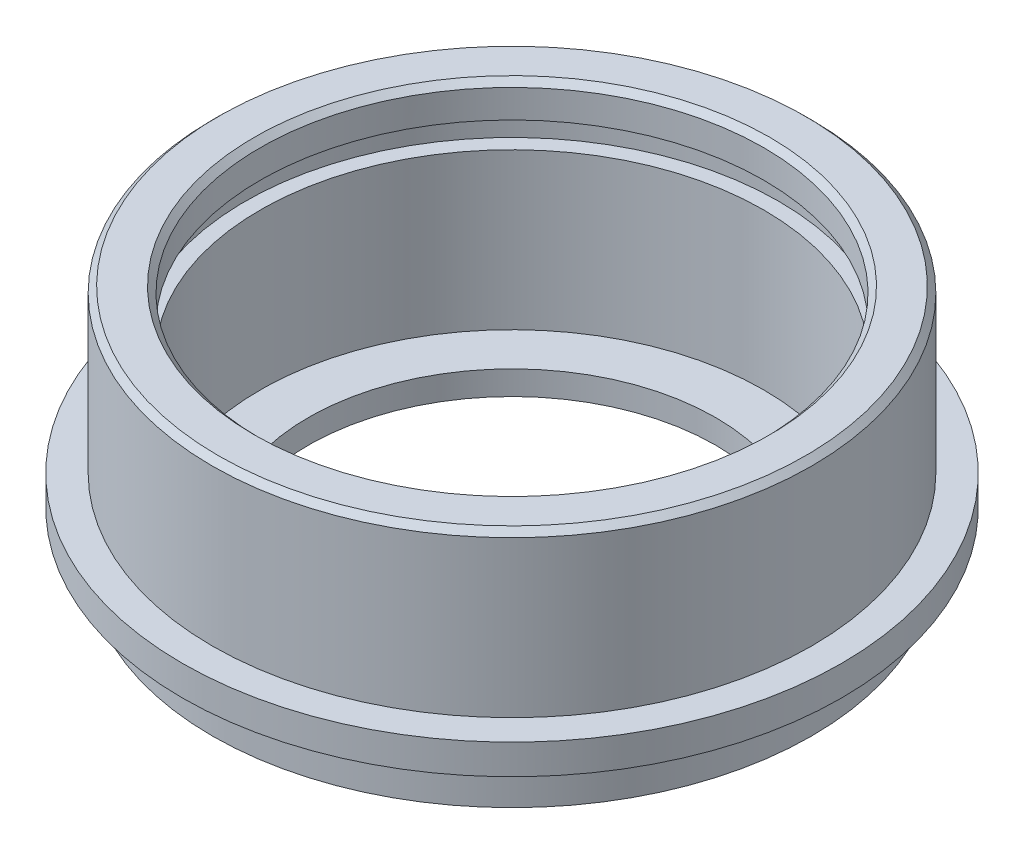
from build123d import *

# Parameters (mm, degrees)
CHAMFER_1_SIZE = 0.5


with BuildPart() as part:
    # Эскиз1 → Повернуть1 (revolve)
    with BuildSketch(Plane.XY):
        Polygon((17, 0), (17, 2), (21, 2), (21, 15), (22.25, 15), (22.25, 17.15), (21, 17.15), (21, 20), (25, 20), (25, 6.5), (27.5, 6.5), (27.5, 4), (25, 4), (25, 0), align=None)
    revolve(axis=Axis((0, 0, 0), (0, 1, 0)))

    # Фаска1
    chamfer_1_edges = [part.edges().sort_by_distance(p)[0] for p in [
        (-25, 20, 0),
        (-21, 20, 0),
    ]]
    chamfer(chamfer_1_edges, length=CHAMFER_1_SIZE)


solid = part.part
